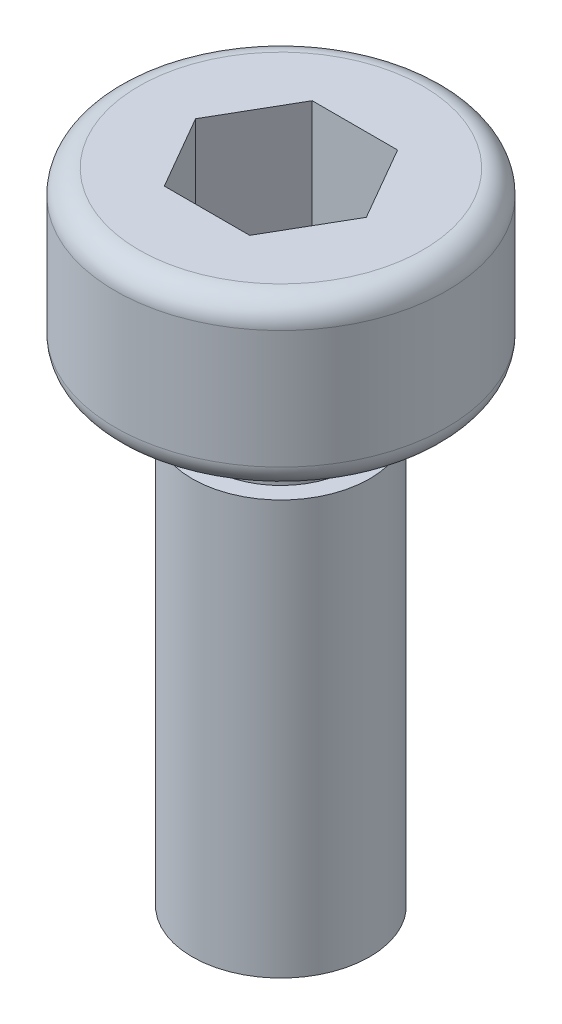
from build123d import *

# Parameters (mm, degrees)
CUT_EXTRUDE_1_DEPTH = 2


with BuildPart() as part:
    # 草图1 → 旋转1 (revolve)
    with BuildSketch(Plane.XY):
        with BuildLine():
            Line((0, 10.8), (-2.4, 10.8))
            ThreePointArc((-2.4, 10.8), (-2.682842712, 10.682842712), (-2.8, 10.4))
            Line((-2.8, 10.4), (-2.8, 8.4))
            ThreePointArc((-2.8, 8.4), (-2.682842712, 8.117157288), (-2.4, 8))
            Line((-2.4, 8), (-1.2, 8))
            Line((-1.2, 8), (-1.2, 7))
            Line((-1.2, 7), (-1.5, 7))
            Line((-1.5, 7), (-1.5, 0))
            Line((-1.5, 0), (0, 0))
            Line((0, 0), (0, 10.8))
        make_face()
    revolve(axis=Axis((0, 0, 0), (0, 1, 0)))

    # 草图2 → 切除-拉伸1 (cut)
    with BuildSketch(Plane(origin=(0, 10.8, 0), x_dir=(1, 0, 0), z_dir=(0, 1, 0))):
        Polygon((-0.721687836, 1.25), (-1.443375673, 0), (-0.721687836, -1.25), (0.721687836, -1.25), (1.443375673, 0), (0.721687836, 1.25), align=None)
    extrude(amount=-CUT_EXTRUDE_1_DEPTH, mode=Mode.SUBTRACT)


solid = part.part
